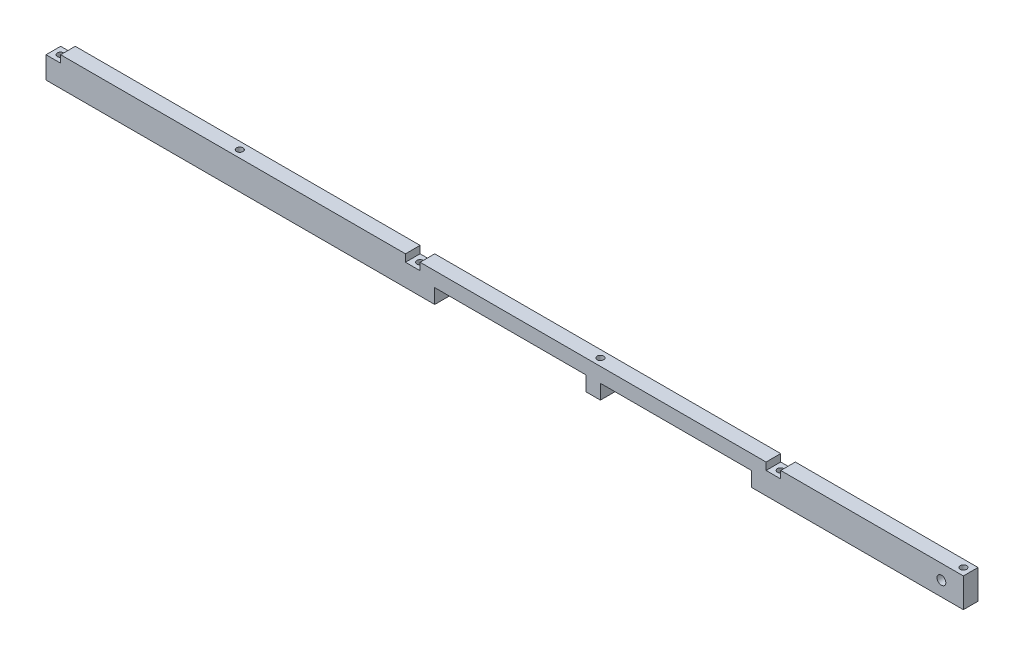
from build123d import *

# Parameters (mm, degrees)
SKETCH1_W                   = 6.35
SKETCH1_H                   = 12.7
BOSS_EXTRUDE1_DEPTH         = 398.018
F_34_0_111_DIAMETER_HOLE1_D = 2.8194
SKETCH6_W                   = 6.35
SKETCH6_H                   = 6.35
CUT_EXTRUDE1_DEPTH          = 7.35
TAP_DRILL_FOR_10_24_TAP1_D  = 3.7973
SKETCH9_W                   = 65.532
SKETCH9_H                   = 6.35
CUT_EXTRUDE3_DEPTH          = 7.35


with BuildPart() as part:
    # Sketch1 → Boss-Extrude1 (new body)
    with BuildSketch(Plane(origin=(0, 0, 0), x_dir=(0, 0, -1), z_dir=(1, 0, 0))):
        with Locations((3.175, 6.35)):
            Rectangle(SKETCH1_W, SKETCH1_H)
    extrude(amount=BOSS_EXTRUDE1_DEPTH)

    # #34 (0.111) Diameter Hole1 (through all)
    with Locations(Plane(origin=(0, 12.7, 0), x_dir=(1, 0, 0), z_dir=(0, 1, 0))):
        with Locations((3.175, 3.175), (159.131, 3.175), (80.899, 3.175), (237.363, 3.175), (315.595, 3.175), (394.843, 3.175)):
            Hole(F_34_0_111_DIAMETER_HOLE1_D / 2)

    # Sketch6 → Cut-Extrude1 (cut, through all)
    with BuildSketch(Plane.XY):
        with Locations((315.595, 12.7)):
            Rectangle(SKETCH6_W, SKETCH6_H)
        with Locations((159.131, 12.7)):
            Rectangle(SKETCH6_W, SKETCH6_H)
        with Locations((3.175, 12.7)):
            Rectangle(SKETCH6_W, SKETCH6_H)
    extrude(amount=-CUT_EXTRUDE1_DEPTH, mode=Mode.SUBTRACT)

    # Tap Drill for #10-24 Tap1 (through all)
    with Locations(Plane.XY):
        with Locations((388.493, 6.35)):
            Hole(TAP_DRILL_FOR_10_24_TAP1_D / 2)

    # Sketch9 → Cut-Extrude3 (cut, through all)
    with BuildSketch(Plane.XY):
        with Locations((201.422, 3.175)):
            Rectangle(SKETCH9_W, SKETCH9_H)
        with Locations((273.304, 3.175)):
            Rectangle(SKETCH9_W, SKETCH9_H)
    extrude(amount=-CUT_EXTRUDE3_DEPTH, mode=Mode.SUBTRACT)


solid = part.part
